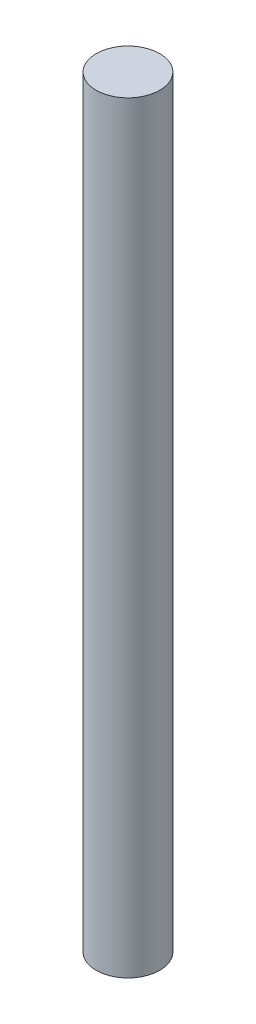
from build123d import *

# Parameters (mm, degrees)
SKETCH1_R           = 5
BOSS_EXTRUDE1_DEPTH = 120


with BuildPart() as part:
    # Sketch1 → Boss-Extrude1 (new body)
    with BuildSketch(Plane(origin=(0, 0, 0), x_dir=(1, 0, 0), z_dir=(0, 1, 0))):
        Circle(SKETCH1_R)
    extrude(amount=BOSS_EXTRUDE1_DEPTH)


solid = part.part
